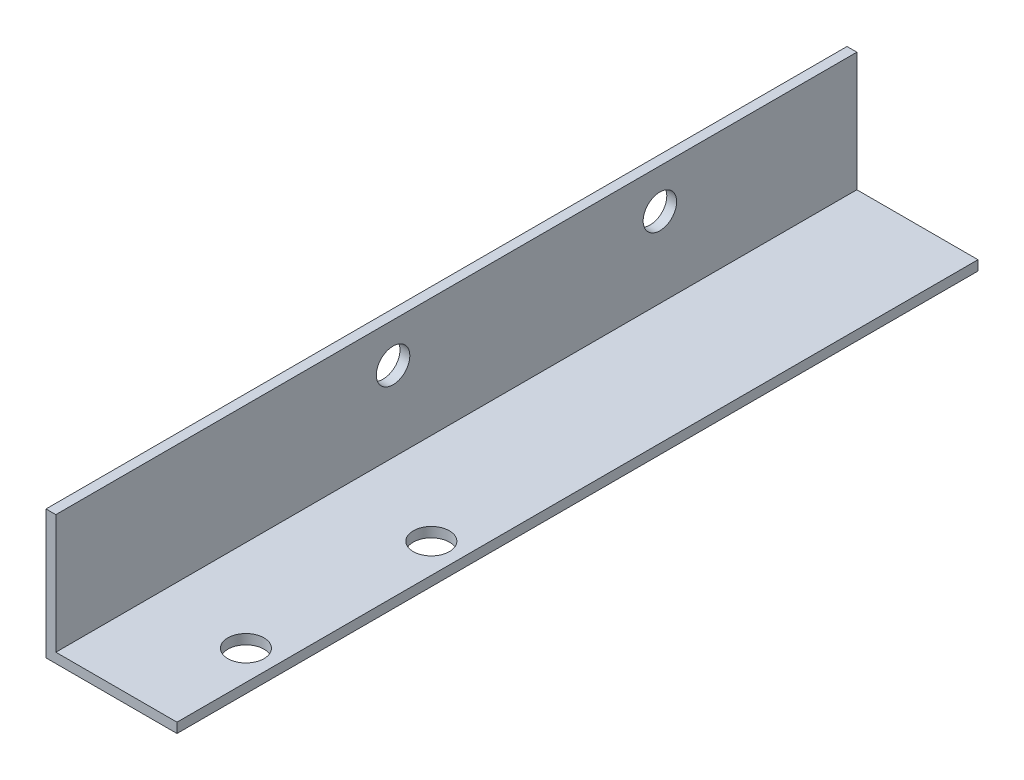
from build123d import *

# Parameters (mm, degrees)
BOSS_EXTRUDE1_DEPTH = 122
SKETCH2_R           = 2.75
CUT_EXTRUDE1_DEPTH  = 20.65
SKETCH3_R           = 2.55
CUT_EXTRUDE2_DEPTH  = 20.95


with BuildPart() as part:
    # Sketch1 → Boss-Extrude1 (new body)
    with BuildSketch(Plane.XY):
        Polygon((0, 18.15), (0, 0), (18.45, 0), (18.45, -1.5), (-1.5, -1.5), (-1.5, 18.15), align=None)
    extrude(amount=BOSS_EXTRUDE1_DEPTH)

    # Sketch2 → Cut-Extrude1 (cut, through all)
    with BuildSketch(Plane(origin=(0, -1.5, 0), x_dir=(-1, 0, 0), z_dir=(0, -1, 0))):
        with Locations((-13.95, -107)):
            Circle(SKETCH2_R)
        with Locations((-13.95, -78.76)):
            Circle(SKETCH2_R)
    extrude(amount=-CUT_EXTRUDE1_DEPTH, mode=Mode.SUBTRACT)

    # Sketch3 → Cut-Extrude2 (cut, through all)
    with BuildSketch(Plane.ZY.offset(1.5)):
        with Locations((30, 12.15)):
            Circle(SKETCH3_R)
        with Locations((70.64, 12.15)):
            Circle(SKETCH3_R)
    extrude(amount=-CUT_EXTRUDE2_DEPTH, mode=Mode.SUBTRACT)


solid = part.part
